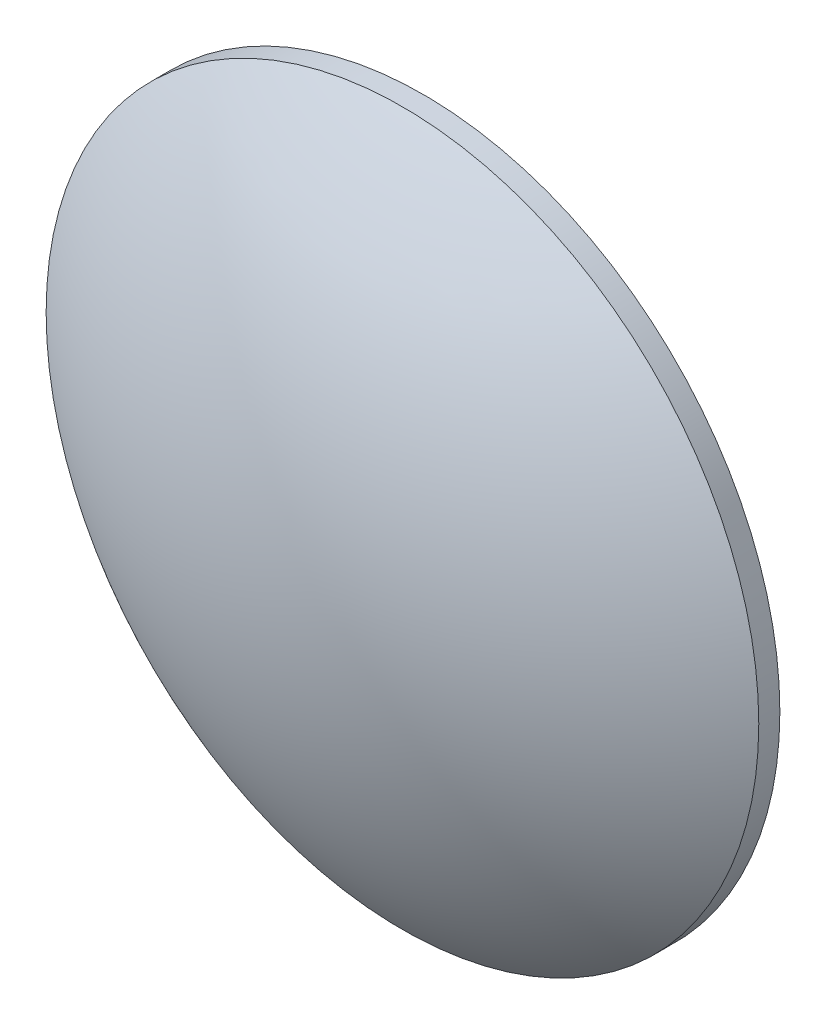
from build123d import *

# Parameters (mm, degrees)
SKETCH2_OUTSIDE_W  = 117.086
SKETCH2_OUTSIDE_H  = 117.086
SKETCH2_OUTSIDE_R  = 25.4
CUT_EXTRUDE1_DEPTH = 86.476
SKETCH3_R          = 25.4
CUT_EXTRUDE2_DEPTH = 76.606


with BuildPart() as part:
    # Sketch1 → Revolve1 (revolve)
    with BuildSketch(Plane.XY):
        with BuildLine():
            Line((0, 42.738), (0, -42.738))
            ThreePointArc((0, -42.738), (-42.738, 0), (0, 42.738))
        make_face()
    revolve(axis=Axis((0, 42.738, 0), (0, -1, 0)))

    # Sketch2 outside → Cut-Extrude1 (cut, through all)
    with BuildSketch(Plane.XY.offset(42.738)):
        Rectangle(SKETCH2_OUTSIDE_W, SKETCH2_OUTSIDE_H)
        Circle(SKETCH2_OUTSIDE_R, mode=Mode.SUBTRACT)
    extrude(amount=-CUT_EXTRUDE1_DEPTH, mode=Mode.SUBTRACT)

    # Sketch3 → Cut-Extrude2 (cut, through all)
    with BuildSketch(Plane.XY.offset(32.868)):
        Circle(SKETCH3_R)
    extrude(amount=-CUT_EXTRUDE2_DEPTH, mode=Mode.SUBTRACT)


solid = part.part
